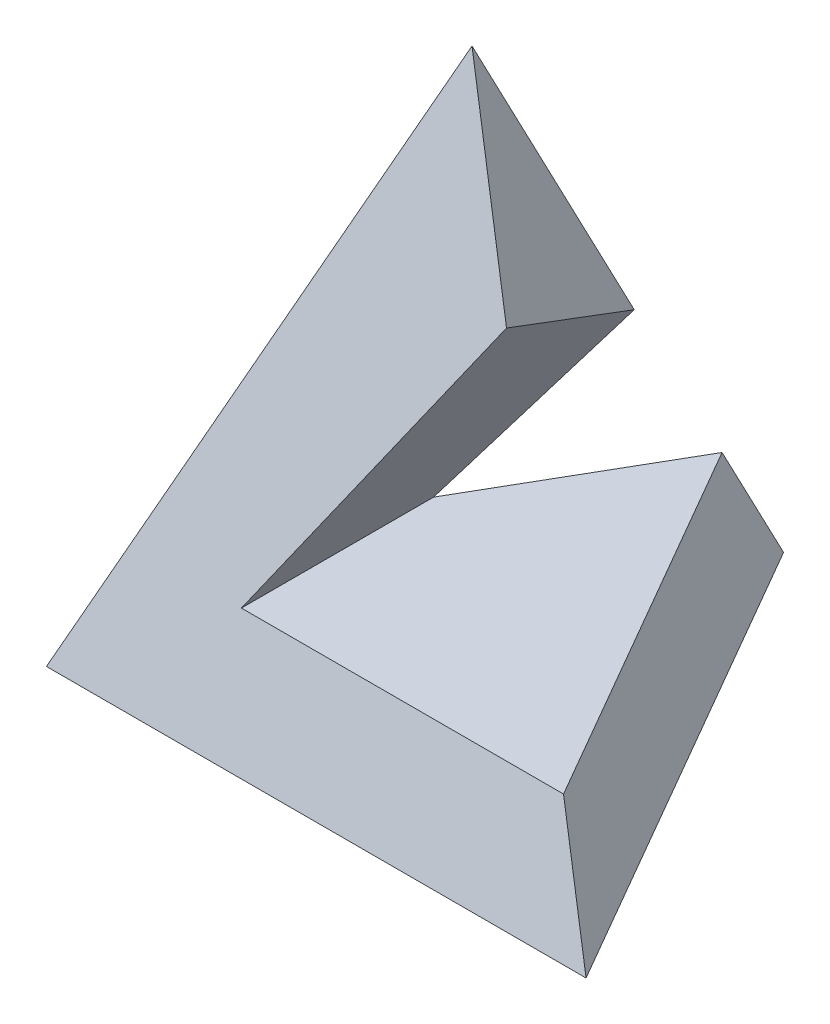
from build123d import *

# Parameters (mm, degrees)
CUT_EXTRUDE_2_DEPTH = 38


with BuildPart() as part:
    # 草图1 → 放样3 section 0
    with BuildSketch(Plane(origin=(0, 0, 0), x_dir=(1, 0, 0), z_dir=(0, 1, 0)), mode=Mode.PRIVATE) as loft_3_s0:
        Polygon((0, 39.837168574), (-34.5, -19.918584287), (34.5, -19.918584287), align=None)
    loft([Vertex(0, 76, 0), loft_3_s0.sketch])

    # 草图11 → 切除-拉伸2 (cut, symmetric)
    with BuildSketch(Plane.XY):
        Polygon((10.440789474, 53), (27.690789474, 15), (-13.5, 15), align=None)
    extrude(amount=CUT_EXTRUDE_2_DEPTH, both=True, mode=Mode.SUBTRACT)


solid = part.part
